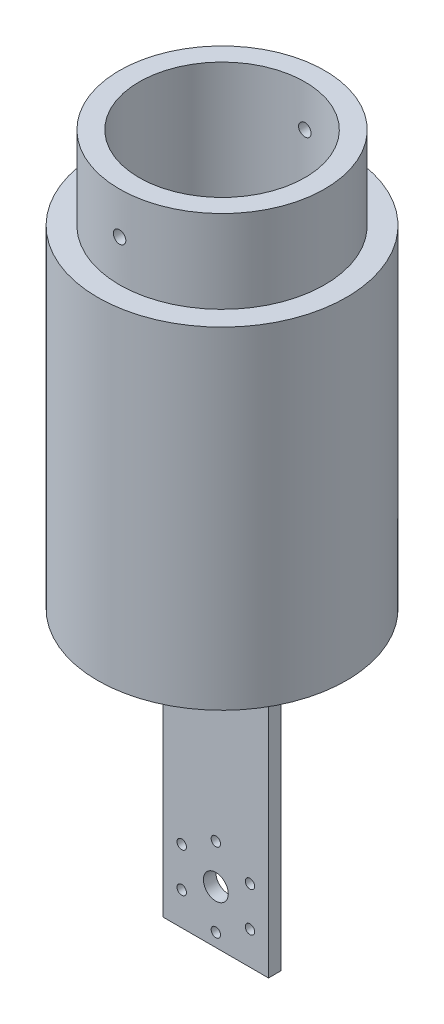
from build123d import *

# Parameters (mm, degrees)
SKETCH2_W                 = 25.4
SKETCH2_H                 = 3
BOSS_EXTRUDE1_DEPTH       = 70
SKETCH4_R                 = 30
BOSS_EXTRUDE2_DEPTH       = 10
SKETCH5_R                 = 30
SKETCH5_R_2               = 20
BOSS_EXTRUDE3_DEPTH       = 70
SKETCH8_R                 = 24.75
SKETCH8_R_2               = 20
BOSS_EXTRUDE4_DEPTH       = 20
SKETCH9_R                 = 1.5
CUT_EXTRUDE4_DEPTH        = 29.5
CUT_EXTRUDE4_DEPTH_BACK   = 32.5
F_4_40_TAPPED_HOLE1_D     = 2.2606
F_4_40_TAPPED_HOLE1_DEPTH = 7.6
F_4_40_TAPPED_HOLE1_TIP   = 0.679152758
SKETCH3_R                 = 3
CUT_EXTRUDE5_DEPTH        = 10


with BuildPart() as part:
    # Sketch2 → Boss-Extrude1 (new body)
    with BuildSketch(Plane(origin=(0, 0, 0), x_dir=(1, 0, 0), z_dir=(0, 1, 0))):
        with Locations((12.7, 1.5)):
            Rectangle(SKETCH2_W, SKETCH2_H)
    extrude(amount=BOSS_EXTRUDE1_DEPTH)

    # Sketch4 → Boss-Extrude2 (add)
    with BuildSketch(Plane(origin=(0, 70, 0), x_dir=(1, 0, 0), z_dir=(0, 1, 0))):
        with Locations((12.7, 1.5)):
            Circle(SKETCH4_R)
    extrude(amount=BOSS_EXTRUDE2_DEPTH)

    # Sketch5 → Boss-Extrude3 (add)
    with BuildSketch(Plane(origin=(0, 80, 0), x_dir=(1, 0, 0), z_dir=(0, 1, 0))):
        with Locations((12.7, 1.5)):
            Circle(SKETCH5_R)
        with Locations((12.7, 1.5)):
            Circle(SKETCH5_R_2, mode=Mode.SUBTRACT)
    extrude(amount=BOSS_EXTRUDE3_DEPTH)

    # Sketch8 → Boss-Extrude4 (add)
    with BuildSketch(Plane(origin=(0, 150, 0), x_dir=(1, 0, 0), z_dir=(0, 1, 0))):
        with Locations((12.7, 1.5)):
            Circle(SKETCH8_R)
        with Locations((12.7, 1.5)):
            Circle(SKETCH8_R_2, mode=Mode.SUBTRACT)
    extrude(amount=BOSS_EXTRUDE4_DEPTH)

    # Sketch9 → Cut-Extrude4 (cut, two sides)
    with BuildSketch(Plane.XY) as cut_extrude4_sk:
        with Locations((12.7, 160)):
            Circle(SKETCH9_R)
    extrude(amount=CUT_EXTRUDE4_DEPTH, mode=Mode.SUBTRACT)
    extrude(cut_extrude4_sk.sketch, amount=-CUT_EXTRUDE4_DEPTH_BACK, mode=Mode.SUBTRACT)

    # #4-40 Tapped Hole1
    with Locations(Plane.XY):
        with Locations((12.7, 22.2), (20.927241336, 17.45), (20.927241336, 7.95), (12.7, 3.2), (4.472758664, 7.95), (4.472758664, 17.45)):
            Hole(F_4_40_TAPPED_HOLE1_D / 2, depth=F_4_40_TAPPED_HOLE1_DEPTH)
            with Locations((0, 0, -(F_4_40_TAPPED_HOLE1_DEPTH + F_4_40_TAPPED_HOLE1_TIP / 2))):  # 118° drill point
                Cone(0, F_4_40_TAPPED_HOLE1_D / 2, F_4_40_TAPPED_HOLE1_TIP, mode=Mode.SUBTRACT)

    # Sketch3 → Cut-Extrude5 (cut)
    with BuildSketch(Plane.XY):
        with Locations((12.7, 12.7)):
            Circle(SKETCH3_R)
    extrude(amount=-CUT_EXTRUDE5_DEPTH, mode=Mode.SUBTRACT)


solid = part.part
